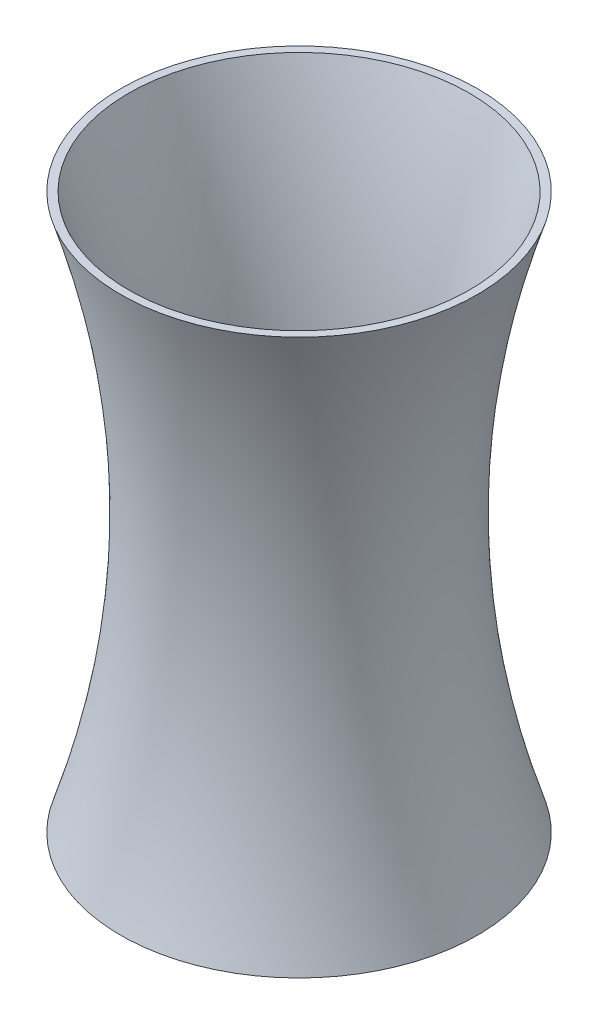
from build123d import *


with BuildPart() as part:
    # Sketch1 → Revolve2 (revolve)
    with BuildSketch(Plane.XY):
        with BuildLine():
            add(Edge.make_bspline(
                [(-54.61, 177.8), (-26.035, 88.9), (-54.61, 0)],
                knots=[0, 0, 0, 1, 1, 1], degree=2))
            Line((-54.61, 177.8), (-57.15, 177.8))
            add(Edge.make_bspline(
                [(-57.15, 177.8), (-28.575, 88.9), (-57.15, 0)],
                knots=[0, 0, 0, 1, 1, 1], degree=2))
            Line((-57.15, 0), (-54.61, 0))
        make_face()
    revolve(axis=Axis((0, 0, 0), (0, 1, 0)))


solid = part.part
